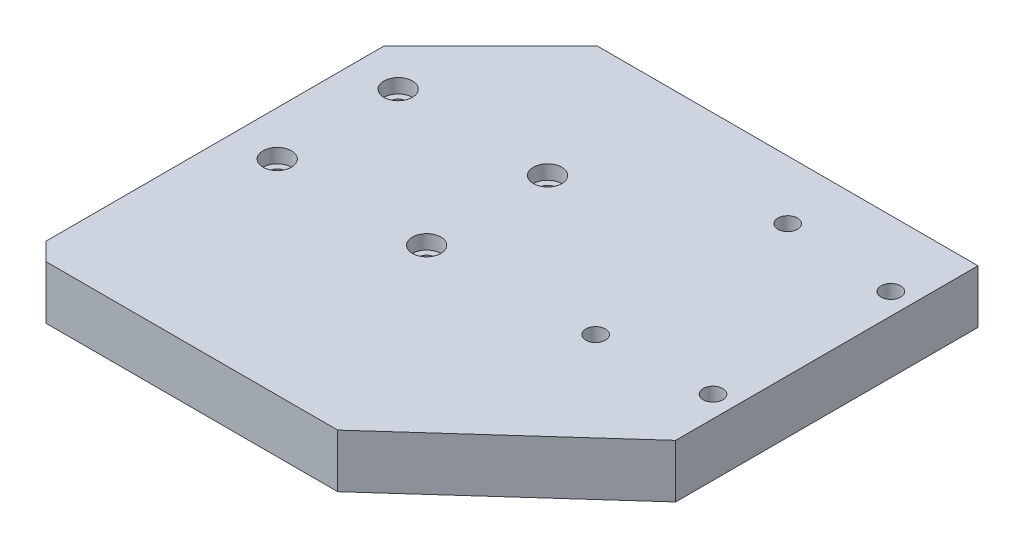
from build123d import *

# Parameters (mm, degrees)
BOSS_EXTRUDE1_DEPTH                             = 15
M5_CLEARANCE_HOLE1_D                            = 5.5
M5_CLEARANCE_HOLE2_D                            = 5.5
CBORE_FOR_M4_SOCKET_HEAD_CAP_SCREW1_D           = 4.5
CBORE_FOR_M4_SOCKET_HEAD_CAP_SCREW1_CBORE_D     = 8
CBORE_FOR_M4_SOCKET_HEAD_CAP_SCREW1_CBORE_DEPTH = 4
HOLE_WIZARD_M51_D                               = 4.2
HOLE_WIZARD_M51_DEPTH                           = 14
HOLE_WIZARD_M51_TIP                             = 1.2618073


with BuildPart() as part:
    # Sketch1 → Boss-Extrude1 (new body)
    with BuildSketch(Plane(origin=(0, 0, 0), x_dir=(1, 0, 0), z_dir=(0, 1, 0))):
        Polygon((0, 100), (30, 130), (137, 130), (137, 120), (137, 45), (87, 0), (5, 0), (0, 5), align=None)
    extrude(amount=BOSS_EXTRUDE1_DEPTH)

    # M5 Clearance Hole1 (through all)
    with Locations(Plane(origin=(0, 15, 0), x_dir=(-1, 0, 0), z_dir=(0, 1, 0))):
        with Locations((-100, -59.5), (-100, -113.5)):
            Hole(M5_CLEARANCE_HOLE1_D / 2)

    # M5 Clearance Hole2 (through all)
    with Locations(Plane(origin=(0, 15, 0), x_dir=(-1, 0, 0), z_dir=(0, 1, 0))):
        with Locations((-131, -111.5), (-131, -61.5)):
            Hole(M5_CLEARANCE_HOLE2_D / 2)

    # CBORE for M4 Socket Head Cap Screw1 (through all)
    with Locations(Plane(origin=(0, 15, 0), x_dir=(-1, 0, 0), z_dir=(0, 1, 0))):
        with Locations((-12.5, -91.5), (-12.5, -57.5), (-54.5, -57.5), (-54.5, -91.5)):
            CounterBoreHole(CBORE_FOR_M4_SOCKET_HEAD_CAP_SCREW1_D / 2, CBORE_FOR_M4_SOCKET_HEAD_CAP_SCREW1_CBORE_D / 2, CBORE_FOR_M4_SOCKET_HEAD_CAP_SCREW1_CBORE_DEPTH)

    # Отверстие обработанное метчиком M51
    with Locations(Plane.ZY):
        with Locations((-50, 7.5), (-20, 7.5)):
            Hole(HOLE_WIZARD_M51_D / 2, depth=HOLE_WIZARD_M51_DEPTH)
            with Locations((0, 0, -(HOLE_WIZARD_M51_DEPTH + HOLE_WIZARD_M51_TIP / 2))):  # 118° drill point
                Cone(0, HOLE_WIZARD_M51_D / 2, HOLE_WIZARD_M51_TIP, mode=Mode.SUBTRACT)


solid = part.part
